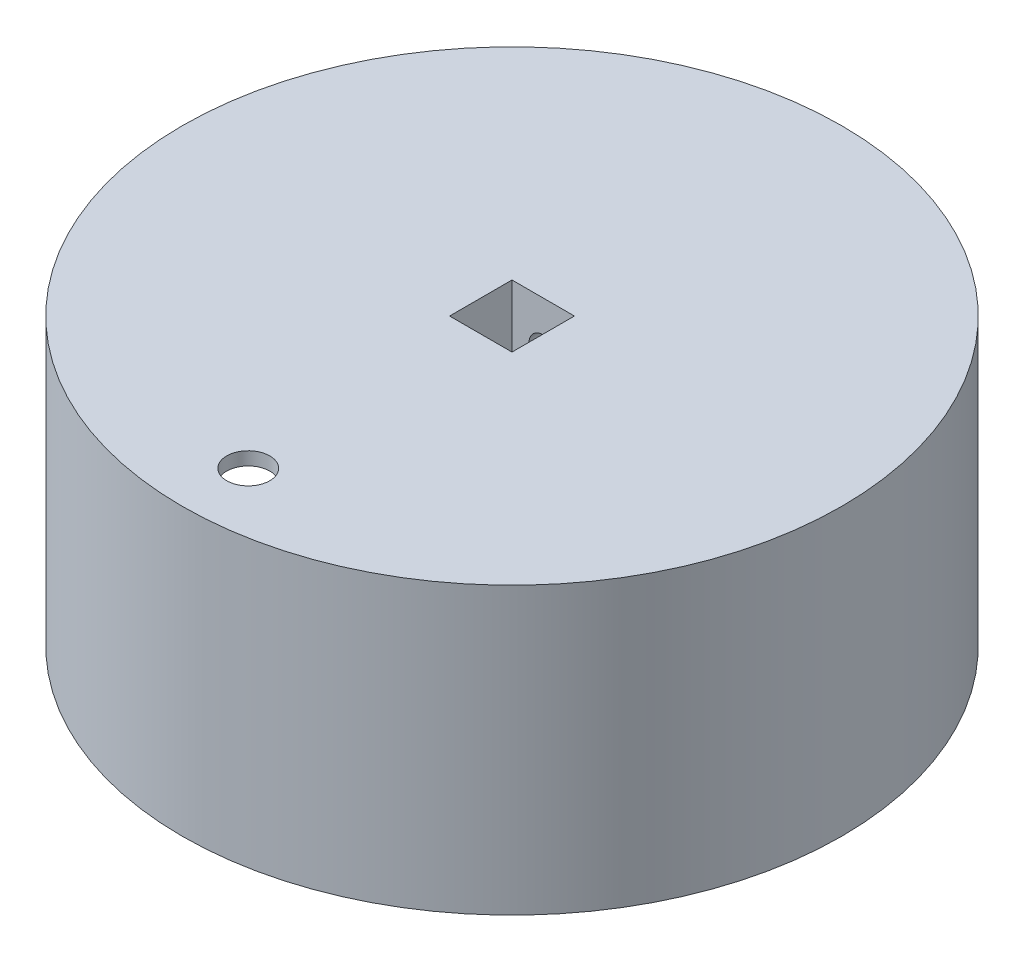
from build123d import *

# Parameters (mm, degrees)
SKETCH1_R                     = 75
BOSS_EXTRUDE1_DEPTH           = 65
SHELL1_T                      = -3
SKETCH2_W                     = 14.2
SKETCH2_H                     = 14.2
CUT_EXTRUDE1_DEPTH            = 125.398553046
BOSS_EXTRUDE2_DEPTH           = 59
CHAMFER2_SIZE                 = 10
SKETCH14_W                    = 18
SKETCH14_H                    = 10
CUT_EXTRUDE7_DEPTH            = 59
SKETCH5_W                     = 24.2
SKETCH5_H                     = 19.2
BOSS_EXTRUDE3_DEPTH           = 5
CUT_EXTRUDE2_REACH            = 130.804
SKETCH6_R                     = 3.25
BOSS_EXTRUDE5_REACH           = 126.399
VIRRANSY_TT_JA_USB_REACH      = 134.047
VIRRANSY_TT_JA_USB_END_RADIUS = 75
BOSS_EXTRUDE4_DEPTH           = 59
FILLET1_R                     = 3
SKETCH9_R                     = 1.25
CUT_EXTRUDE4_DEPTH            = 15
CIRPATTERN1_COUNT             = 4
FILLET1_OF_CIRPATTERN1_R      = 3
SKETCH10_R                    = 4.9
MIKROFONI_DEPTH               = 123.857641368
SKETCH11_R                    = 1.25
CUT_EXTRUDE6_DEPTH            = 15
SKETCH13_R                    = 3.5
SKETCH13_R_2                  = 0.75
BOSS_EXTRUDE6_DEPTH           = 4
CHAMFER3_SIZE                 = 1


with BuildPart() as part:
    # Sketch1 → Boss-Extrude1 (new body)
    with BuildSketch(Plane(origin=(0, 0, 0), x_dir=(1, 0, 0), z_dir=(0, 1, 0))):
        with Locations(Location((0, 0, 0), (0, 0, 270))):
            Circle(SKETCH1_R)
    extrude(amount=BOSS_EXTRUDE1_DEPTH)

    # Shell1
    shell1_openings = [part.faces().sort_by_distance(p)[0] for p in [
        (0, 0, 0),
    ]]
    offset(amount=SHELL1_T, openings=shell1_openings, kind=Kind.INTERSECTION)

    # Sketch2 → Cut-Extrude1 (cut, through all)
    with BuildSketch(Plane(origin=(0, 65, 0), x_dir=(1, 0, 0), z_dir=(0, 1, 0))):
        Rectangle(SKETCH2_W, SKETCH2_H)
    extrude(amount=-CUT_EXTRUDE1_DEPTH, mode=Mode.SUBTRACT)

    # Sketch3 → Boss-Extrude2 (add)
    with BuildSketch(Plane.XZ.offset(-62)):
        Polygon((-7.1, 7.1), (-7.1, -7.1), (7.1, -7.1), (7.1, 7.1), (12.1, 7.1), (12.1, -12.1), (-12.1, -12.1), (-12.1, 7.1), align=None)
    extrude(amount=BOSS_EXTRUDE2_DEPTH)

    # Chamfer2
    chamfer2_edges = [part.edges().sort_by_distance(p)[0] for p in [
        (9.6, 62, 7.1),
        (12.1, 62, -2.5),
        (0, 62, -12.1),
        (-12.1, 62, -2.5),
        (-9.6, 62, 7.1),
    ]]
    chamfer(chamfer2_edges, length=CHAMFER2_SIZE)

    # Sketch14 → Cut-Extrude7 (cut)
    with BuildSketch(Plane.XZ.offset(-3)):
        with Locations((0, -17.1)):
            Rectangle(SKETCH14_W, SKETCH14_H)
    extrude(amount=-CUT_EXTRUDE7_DEPTH, mode=Mode.SUBTRACT)

    # Sketch5 → Boss-Extrude3 (add)
    with BuildSketch(Plane.XZ.offset(-3)):
        with Locations((0, -2.5)):
            Rectangle(SKETCH5_W, SKETCH5_H)
    extrude(amount=-BOSS_EXTRUDE3_DEPTH)

    # Sketch6 → Cut-Extrude2 (cut, up to next)
    with BuildSketch(Plane.XY.offset(-7.1), mode=Mode.PRIVATE) as cut_extrude2_sk1:
        with Locations((0, 54.5)):
            Circle(SKETCH6_R)
    cut_extrude2_tool1 = extrude(cut_extrude2_sk1.sketch, amount=-CUT_EXTRUDE2_REACH, mode=Mode.PRIVATE) & part.part
    # Sketch6 → Cut-Extrude2 (cut, up to next)
    with BuildSketch(Plane.XY.offset(-7.1), mode=Mode.PRIVATE) as cut_extrude2_sk2:
        with Locations((0, 19.5)):
            Circle(SKETCH6_R)
    cut_extrude2_tool2 = extrude(cut_extrude2_sk2.sketch, amount=-CUT_EXTRUDE2_REACH, mode=Mode.PRIVATE) & part.part
    add(cut_extrude2_tool1.solids().sort_by_distance((0, 54.5, -7.1))[0], mode=Mode.SUBTRACT)
    add(cut_extrude2_tool2.solids().sort_by_distance((0, 19.5, -7.1))[0], mode=Mode.SUBTRACT)

    # Sketch12 → Boss-Extrude5 (add, up to next)
    with BuildSketch(Plane.XZ, mode=Mode.PRIVATE) as boss_extrude5_sk1:
        with BuildLine():
            Line((-10, -71.30217388), (10, -71.30217388))
            ThreePointArc((10, -71.30217388), (0, -72), (-10, -71.30217388))
        make_face()
    boss_extrude5_tool1 = extrude(boss_extrude5_sk1.sketch, amount=-BOSS_EXTRUDE5_REACH, mode=Mode.PRIVATE) - part.part
    add(boss_extrude5_tool1.solids().sort_by_distance((0, 0, -71.581421))[0])

    # Virransyöttö ja USB: up to this cylinder (the profile starts inside it)
    virransy_tt_ja_usb_end = Plane(origin=(0, 33.9, 0), z_dir=(0, -1, 0)) * Cylinder(VIRRANSY_TT_JA_USB_END_RADIUS, 462.894, mode=Mode.PRIVATE)
    # Sketch7 → Virransyöttö ja USB (cut, up to the surface)
    with BuildSketch(Plane.XY.offset(-12.1), mode=Mode.PRIVATE) as virransy_tt_ja_usb_sk1:
        with BuildLine():
            Line((-5.25, 14.90473751), (-5.25, 9.09526249))
            ThreePointArc((-5.25, 9.09526249), (0, 6), (5.25, 9.09526249))
            Line((5.25, 9.09526249), (5.25, 14.90473751))
            ThreePointArc((5.25, 14.90473751), (0, 18), (-5.25, 14.90473751))
        make_face()
    virransy_tt_ja_usb_tool1 = extrude(virransy_tt_ja_usb_sk1.sketch, amount=-VIRRANSY_TT_JA_USB_REACH, mode=Mode.PRIVATE) & virransy_tt_ja_usb_end
    add(virransy_tt_ja_usb_tool1.solids().sort_by_distance((0, 12, -12.1))[0], mode=Mode.SUBTRACT)
    # Sketch7 → Virransyöttö ja USB (cut, up to the surface)
    with BuildSketch(Plane.XY.offset(-12.1), mode=Mode.PRIVATE) as virransy_tt_ja_usb_sk2:
        with BuildLine():
            Line((3, 59.8), (-3, 59.8))
            ThreePointArc((-3, 59.8), (-5.121320344, 58.921320344), (-6, 56.8))
            Line((-6, 56.8), (-6, 54.8))
            ThreePointArc((-6, 54.8), (-5.121320344, 52.678679656), (-3, 51.8))
            Line((-3, 51.8), (3, 51.8))
            ThreePointArc((3, 51.8), (5.121320344, 52.678679656), (6, 54.8))
            Line((6, 54.8), (6, 56.8))
            ThreePointArc((6, 56.8), (5.121320344, 58.921320344), (3, 59.8))
        make_face()
    virransy_tt_ja_usb_tool2 = extrude(virransy_tt_ja_usb_sk2.sketch, amount=-VIRRANSY_TT_JA_USB_REACH, mode=Mode.PRIVATE) & virransy_tt_ja_usb_end
    add(virransy_tt_ja_usb_tool2.solids().sort_by_distance((0, 55.8, -12.1))[0], mode=Mode.SUBTRACT)

    # Sketch8 → Boss-Extrude4 (add)
    with BuildSketch(Plane.XZ.offset(-62)):
        with BuildLine():
            ThreePointArc((54.916371086, 46.563850643), (50.911688245, 50.911688245), (46.563850643, 54.916371086))
            ThreePointArc((46.563850643, 54.916371086), (43.133513652, 43.133513652), (54.916371086, 46.563850643))
        make_face()
    boss_extrude4 = extrude(amount=BOSS_EXTRUDE4_DEPTH)

    # Fillet1
    fillet1_edges = [part.edges().sort_by_distance(p)[0] for p in [
        (54.916371086, 32.5, 46.563850643),
        (46.563850643, 32.5, 54.916371086),
    ]]
    fillet(fillet1_edges, radius=FILLET1_R)

    # Sketch9 → Cut-Extrude4 (cut)
    with BuildSketch(Plane.XZ.offset(-3)):
        with Locations(Location((45.961940777, 45.961940777, 0), (0, 0, 270))):
            Circle(SKETCH9_R)
    cut_extrude4 = extrude(amount=-CUT_EXTRUDE4_DEPTH, mode=Mode.SUBTRACT)

    # CirPattern1: Boss-Extrude4, Cut-Extrude4 ×4 about axis
    cirpattern1_axis = Axis((0, 0, 0), (0, 1, 0))
    add([boss_extrude4.rotate(cirpattern1_axis, i * 360 / CIRPATTERN1_COUNT) for i in range(1, CIRPATTERN1_COUNT)])
    add([cut_extrude4.rotate(cirpattern1_axis, i * 360 / CIRPATTERN1_COUNT) for i in range(1, CIRPATTERN1_COUNT)], mode=Mode.SUBTRACT)

    # Fillet1 of CirPattern1
    fillet1_of_cirpattern1_edges = [part.edges().sort_by_distance(p)[0] for p in [
        (46.563850643, 32.5, -54.916371086),
        (54.916371086, 32.5, -46.563850643),
        (-54.916371086, 32.5, -46.563850643),
        (-46.563850643, 32.5, -54.916371086),
        (-46.563850643, 32.5, 54.916371086),
        (-54.916371086, 32.5, 46.563850643),
    ]]
    fillet(fillet1_of_cirpattern1_edges, radius=FILLET1_OF_CIRPATTERN1_R)

    # Sketch10 → Mikrofoni (cut, through all)
    with BuildSketch(Plane.XZ.offset(-62)):
        with Locations(Location((0, 60, 0), (0, 0, 270))):
            Circle(SKETCH10_R)
    extrude(amount=-MIKROFONI_DEPTH, mode=Mode.SUBTRACT)

    # Sketch11 → Cut-Extrude6 (cut)
    with BuildSketch(Plane.XZ.offset(-3)):
        with Locations(Location((0, 0, 0), (0, 0, 270))):
            Circle(SKETCH11_R)
    extrude(amount=-CUT_EXTRUDE6_DEPTH, mode=Mode.SUBTRACT)

    # Sketch13 → Boss-Extrude6 (add)
    with BuildSketch(Plane.XZ.offset(-62)):
        with Locations((8.845, -68.30217388)):
            Circle(SKETCH13_R)
        with Locations(Location((8.845, -68.30217388, 0), (0, 0, 270))):
            Circle(SKETCH13_R_2, mode=Mode.SUBTRACT)
        with Locations(Location((-10.605, -39.80217388, 0), (0, 0, 90))):
            Circle(SKETCH13_R)
        with Locations(Location((-10.605, -39.80217388, 0), (0, 0, 270))):
            Circle(SKETCH13_R_2, mode=Mode.SUBTRACT)
        with Locations(Location((-7.43, 33.25, 0), (0, 0, 90))):
            Circle(SKETCH13_R)
        with Locations(Location((-7.43, 33.25, 0), (0, 0, 270))):
            Circle(SKETCH13_R_2, mode=Mode.SUBTRACT)
        with Locations(Location((7.43, 33.25, 0), (0, 0, 90))):
            Circle(SKETCH13_R)
        with Locations(Location((7.43, 33.25, 0), (0, 0, 90))):
            Circle(SKETCH13_R_2, mode=Mode.SUBTRACT)
    extrude(amount=BOSS_EXTRUDE6_DEPTH)

    # Chamfer3
    chamfer3_edges = [part.edges().sort_by_distance(p)[0] for p in [
        (8.732112335, 62, -64.803994871),
        (-10.605, 62, -43.30217388),
        (-7.43, 62, 29.75),
        (7.43, 62, 29.75),
    ]]
    chamfer(chamfer3_edges, length=CHAMFER3_SIZE)


solid = part.part
